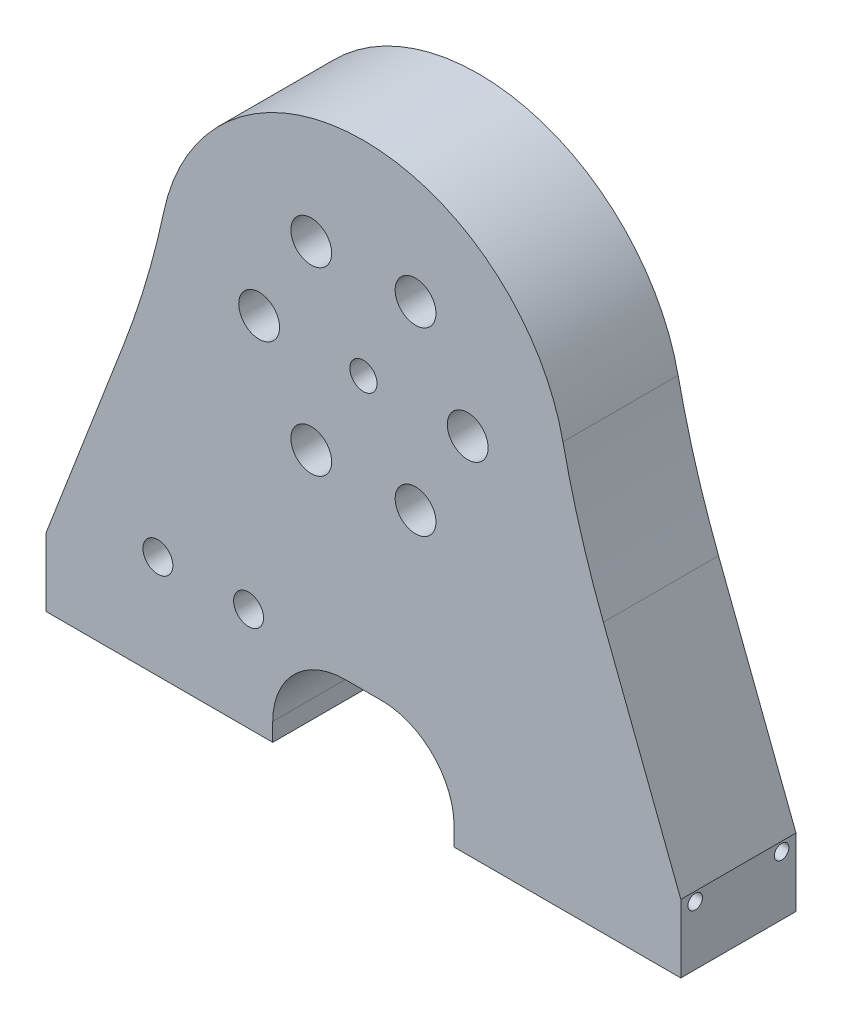
from build123d import *

# Parameters (mm, degrees)
SKETCH2_W                 = 70
SKETCH2_H                 = 70
BOSS_EXTRUDE1_DEPTH       = 6.35
CHAMFER1_SIZE             = 10
SKETCH3_R                 = 1.5
CUT_EXTRUDE1_DEPTH        = 13.7
M4_CLEARANCE_HOLE1_D      = 4.5
CUT_EXTRUDE2_DEPTH        = 13.7
FILLET1_R                 = 100
CUT_EXTRUDE3_DEPTH        = 13.7
M4X0_7_TAPPED_HOLE1_D     = 3.3
M4X0_7_TAPPED_HOLE1_DEPTH = 13
M4X0_7_TAPPED_HOLE1_TIP   = 0.991420021
M4X0_7_TAPPED_HOLE2_D     = 3.3
M2X0_4_TAPPED_HOLE1_D     = 1.6
M2X0_4_TAPPED_HOLE1_DEPTH = 12
M2X0_4_TAPPED_HOLE1_TIP   = 0.480688495


with BuildPart() as part:
    # Sketch2 → Boss-Extrude1 (new body, symmetric)
    with BuildSketch(Plane.XY):
        Rectangle(SKETCH2_W, SKETCH2_H)
    extrude(amount=BOSS_EXTRUDE1_DEPTH, both=True)

    # Chamfer1
    chamfer1_edges = [part.edges().sort_by_distance(p)[0] for p in [
        (-35, 35, 0),
        (35, 35, 0),
    ]]
    chamfer(chamfer1_edges, length=CHAMFER1_SIZE)

    # Sketch3 → Cut-Extrude1 (cut, through all)
    with BuildSketch(Plane(origin=(0, 0, -6.35), x_dir=(-1, 0, 0), z_dir=(0, 0, -1))):
        with Locations((0, 5)):
            Circle(SKETCH3_R)
    extrude(amount=-CUT_EXTRUDE1_DEPTH, mode=Mode.SUBTRACT)

    # M4 Clearance Hole1 (through all)
    with Locations(Plane(origin=(0, 0, -6.35), x_dir=(-1, 0, 0), z_dir=(0, 0, -1))):
        with Locations((5.75, 14.959292144), (-5.75, 14.959292144), (-11.5, 5), (-5.75, -4.959292144), (5.75, -4.959292144), (11.5, 5)):
            Hole(M4_CLEARANCE_HOLE1_D / 2)

    # Sketch6 → Cut-Extrude2 (cut, through all)
    with BuildSketch(Plane(origin=(0, 0, -6.35), x_dir=(-1, 0, 0), z_dir=(0, 0, -1))):
        with BuildLine():
            Line((-35, -27.5), (-22.5, 5))
            ThreePointArc((-22.5, 5), (0, 27.5), (22.5, 5))
            Line((22.5, 5), (35, -27.5))
            Line((35, -27.5), (35, 25))
            Line((35, 25), (25, 35))
            Line((25, 35), (-25, 35))
            Line((-25, 35), (-35, 25))
            Line((-35, 25), (-35, -27.5))
        make_face()
    extrude(amount=-CUT_EXTRUDE2_DEPTH, mode=Mode.SUBTRACT)

    # Fillet1
    fillet1_edges = [part.edges().sort_by_distance(p)[0] for p in [
        (-22.5, 5, 0),
        (22.5, 5, 0),
    ]]
    fillet(fillet1_edges, radius=FILLET1_R)

    # Sketch7 → Cut-Extrude3 (cut, through all)
    with BuildSketch(Plane(origin=(0, 0, -6.35), x_dir=(-1, 0, 0), z_dir=(0, 0, -1))):
        with BuildLine():
            Line((-10, -35), (10, -35))
            Line((10, -35), (10, -33))
            ThreePointArc((10, -33), (7.656854249, -27.343145751), (2, -25))
            Line((2, -25), (-2, -25))
            ThreePointArc((-2, -25), (-7.656854249, -27.343145751), (-10, -33))
            Line((-10, -33), (-10, -35))
        make_face()
    extrude(amount=-CUT_EXTRUDE3_DEPTH, mode=Mode.SUBTRACT)

    # M4x0.7 Tapped Hole1
    with Locations(Plane(origin=(0, -35, 0), x_dir=(-1, 0, 0), z_dir=(0, -1, 0))):
        with Locations((-27.5, 0), (-17.5, 0), (17.5, 0), (27.5, 0)):
            Hole(M4X0_7_TAPPED_HOLE1_D / 2, depth=M4X0_7_TAPPED_HOLE1_DEPTH)
            with Locations((0, 0, -(M4X0_7_TAPPED_HOLE1_DEPTH + M4X0_7_TAPPED_HOLE1_TIP / 2))):  # 118° drill point
                Cone(0, M4X0_7_TAPPED_HOLE1_D / 2, M4X0_7_TAPPED_HOLE1_TIP, mode=Mode.SUBTRACT)

    # M4x0.7 Tapped Hole2 (through all)
    with Locations(Plane(origin=(0, 0, -6.35), x_dir=(-1, 0, 0), z_dir=(0, 0, -1))):
        with Locations((12.662387957, -23.625), (22.662387957, -23.625)):
            Hole(M4X0_7_TAPPED_HOLE2_D / 2)

    # M2x0.4 Tapped Hole1
    with Locations(Plane(origin=(35, 0, 0), x_dir=(0, 0, -1), z_dir=(1, 0, 0))):
        with Locations((-4.765, -28.5), (4.765, -28.5)):
            Hole(M2X0_4_TAPPED_HOLE1_D / 2, depth=M2X0_4_TAPPED_HOLE1_DEPTH)
            with Locations((0, 0, -(M2X0_4_TAPPED_HOLE1_DEPTH + M2X0_4_TAPPED_HOLE1_TIP / 2))):  # 118° drill point
                Cone(0, M2X0_4_TAPPED_HOLE1_D / 2, M2X0_4_TAPPED_HOLE1_TIP, mode=Mode.SUBTRACT)


solid = part.part
